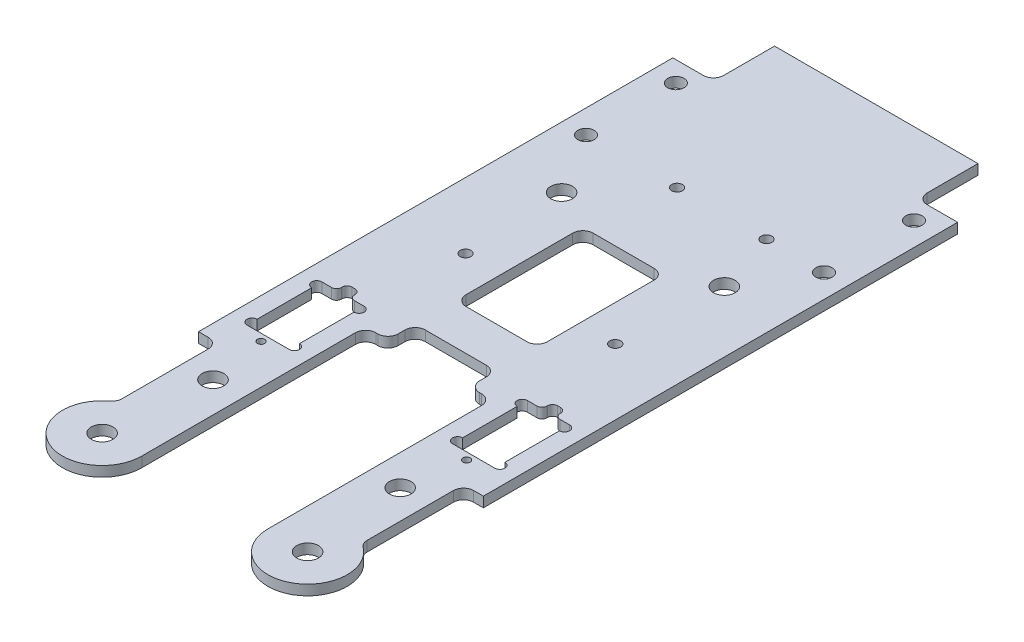
from build123d import *

# Parameters (mm, degrees)
SKETCH1_W           = 88.9
SKETCH1_H           = 228.6
BOSS_EXTRUDE1_DEPTH = 3.175
SKETCH12_R          = 3.3782
SKETCH12_W          = 39.37
SKETCH12_H          = 63.5
CUT_EXTRUDE13_DEPTH = 4.175
SKETCH14_R          = 2.5527
CUT_EXTRUDE15_DEPTH = 4.175
SKETCH15_W          = 88.9
SKETCH15_H          = 57.15
CUT_EXTRUDE16_DEPTH = 4.175
FILLET1_R           = 3.175
SKETCH18_R          = 1.6891
CUT_EXTRUDE18_DEPTH = 4.175
SKETCH16_R          = 3.3782
BOSS_EXTRUDE2_DEPTH = 3.175
SKETCH19_R          = 3.3782
CUT_EXTRUDE19_DEPTH = 4.175
SKETCH20_R          = 1.143
CUT_EXTRUDE20_DEPTH = 4.175
SKETCH21_W          = 88.9
SKETCH21_H          = 3.175
BOSS_EXTRUDE3_DEPTH = 19.05
CUT_EXTRUDE21_DEPTH = 4.175
CUT_EXTRUDE22_DEPTH = 4.175


with BuildPart() as part:
    # Sketch1 → Boss-Extrude1 (new body)
    with BuildSketch(Plane(origin=(0, 0, 0), x_dir=(1, 0, 0), z_dir=(0, 1, 0))):
        Rectangle(SKETCH1_W, SKETCH1_H)
    extrude(amount=BOSS_EXTRUDE1_DEPTH)

    # Sketch12 → Cut-Extrude13 (cut, through all)
    with BuildSketch(Plane(origin=(0, 3.175, 0), x_dir=(1, 0, 0), z_dir=(0, 1, 0))):
        with Locations((29.21, -44.45)):
            Circle(SKETCH12_R)
        with Locations((-29.21, -44.45)):
            Circle(SKETCH12_R)
        with Locations((0, -38.1)):
            Rectangle(SKETCH12_W, SKETCH12_H)
    extrude(amount=-CUT_EXTRUDE13_DEPTH, mode=Mode.SUBTRACT)

    # Sketch14 → Cut-Extrude15 (cut, through all)
    with BuildSketch(Plane(origin=(0, 0, 0), x_dir=(-1, 0, 0), z_dir=(0, -1, 0))):
        with Locations((-37.1475, 107.95)):
            Circle(SKETCH14_R)
        with Locations((-37.1475, 79.883)):
            Circle(SKETCH14_R)
        with Locations((37.1475, 107.95)):
            Circle(SKETCH14_R)
        with Locations((37.1475, 79.883)):
            Circle(SKETCH14_R)
    extrude(amount=-CUT_EXTRUDE15_DEPTH, mode=Mode.SUBTRACT)

    # Sketch15 → Cut-Extrude16 (cut, through all)
    with BuildSketch(Plane.XZ):
        with Locations((0, 85.725)):
            Rectangle(SKETCH15_W, SKETCH15_H)
        with BuildLine():
            Line((12.7, -51.308), (12.7, -17.991666667))
            ThreePointArc((12.7, -17.991666667), (11.77006403, -15.746602636), (9.525, -14.816666667))
            Line((9.525, -14.816666667), (-9.525, -14.816666667))
            ThreePointArc((-9.525, -14.816666667), (-11.77006403, -15.746602636), (-12.7, -17.991666667))
            Line((-12.7, -17.991666667), (-12.7, -51.308))
            ThreePointArc((-12.7, -51.308), (-11.77006403, -53.55306403), (-9.525, -54.483))
            Line((-9.525, -54.483), (9.525, -54.483))
            ThreePointArc((9.525, -54.483), (11.77006403, -53.55306403), (12.7, -51.308))
        make_face()
        with BuildLine():
            Line((12.7, 6.35), (-12.7, 6.35))
            Line((-12.7, 6.35), (-12.7, 1.058333333))
            ThreePointArc((-12.7, 1.058333333), (-11.77006403, -1.186730697), (-9.525, -2.116666667))
            Line((-9.525, -2.116666667), (9.525, -2.116666667))
            ThreePointArc((9.525, -2.116666667), (11.77006403, -1.186730697), (12.7, 1.058333333))
            Line((12.7, 1.058333333), (12.7, 6.35))
        make_face()
    extrude(amount=-CUT_EXTRUDE16_DEPTH, mode=Mode.SUBTRACT)

    # Fillet1
    fillet1_edges = [part.edges().sort_by_distance(p)[0] for p in [
        (19.685, 1.5875, 6.35),
        (-19.685, 1.5875, 6.35),
        (-12.7, 1.5875, 6.35),
        (12.7, 1.5875, 6.35),
    ]]
    fillet(fillet1_edges, radius=FILLET1_R)

    # Sketch18 → Cut-Extrude18 (cut, through all)
    with BuildSketch(Plane(origin=(0, 3.175, 0), x_dir=(1, 0, 0), z_dir=(0, 1, 0))):
        with Locations((-23.9014, 29.083)):
            Circle(SKETCH18_R)
        with Locations((23.9014, 27.98318)):
            Circle(SKETCH18_R)
        with Locations((-8.70204, 79.883)):
            Circle(SKETCH18_R)
        with Locations((19.19986, 79.883)):
            Circle(SKETCH18_R)
    extrude(amount=-CUT_EXTRUDE18_DEPTH, mode=Mode.SUBTRACT)

    # Sketch16 → Boss-Extrude2 (add)
    with BuildSketch(Plane(origin=(0, 3.175, 0), x_dir=(1, 0, 0), z_dir=(0, 1, 0))):
        with BuildLine():
            Line((-44.45, -57.15), (-44.45, -76.2))
            ThreePointArc((-44.45, -76.2), (-32.0675, -88.5825), (-19.685, -76.2))
            Line((-19.685, -76.2), (-19.685, -57.15))
            Line((-19.685, -57.15), (-44.45, -57.15))
        make_face()
        with Locations((-32.0675, -76.2)):
            Circle(SKETCH16_R, mode=Mode.SUBTRACT)
        with BuildLine():
            ThreePointArc((44.45, -76.2), (32.0675, -88.5825), (19.685, -76.2))
            Line((19.685, -76.2), (19.685, -57.15))
            Line((19.685, -57.15), (44.45, -57.15))
            Line((44.45, -57.15), (44.45, -76.2))
        make_face()
        with Locations((32.0675, -76.2)):
            Circle(SKETCH16_R, mode=Mode.SUBTRACT)
    extrude(amount=-BOSS_EXTRUDE2_DEPTH)

    # Sketch19 → Cut-Extrude19 (cut, through all)
    with BuildSketch(Plane(origin=(0, 3.175, 0), x_dir=(1, 0, 0), z_dir=(0, 1, 0))):
        with Locations((-25.4, 60.536666667)):
            Circle(SKETCH19_R)
        with Locations((25.4, 60.536666667)):
            Circle(SKETCH19_R)
    extrude(amount=-CUT_EXTRUDE19_DEPTH, mode=Mode.SUBTRACT)

    # Sketch20 → Cut-Extrude20 (cut, through all)
    with BuildSketch(Plane(origin=(0, 3.175, 0), x_dir=(1, 0, 0), z_dir=(0, 1, 0))):
        with Locations((-32.0675, -26.58657951)):
            Circle(SKETCH20_R)
        with Locations((32.0675, -26.58657951)):
            Circle(SKETCH20_R)
        with BuildLine():
            Line((-25.4635, -24.384), (-38.6715, -24.384))
            ThreePointArc((-38.6715, -24.384), (-40.259, -22.7965), (-38.6715, -21.209))
            Line((-38.6715, -21.209), (-38.6715, -4.191))
            ThreePointArc((-38.6715, -4.191), (-40.259, -2.6035), (-38.6715, -1.016))
            Line((-38.6715, -1.016), (-35.687, -1.016))
            ThreePointArc((-35.687, -1.016), (-34.564467985, -0.551032015), (-34.0995, 0.5715))
            Line((-34.0995, 0.5715), (-34.0995, 0.6985))
            ThreePointArc((-34.0995, 0.6985), (-33.634532015, 1.821032015), (-32.512, 2.286))
            Line((-32.512, 2.286), (-31.623, 2.286))
            ThreePointArc((-31.623, 2.286), (-30.500467985, 1.821032015), (-30.0355, 0.6985))
            Line((-30.0355, 0.6985), (-30.0355, 0.5715))
            ThreePointArc((-30.0355, 0.5715), (-29.570532015, -0.551032015), (-28.448, -1.016))
            Line((-28.448, -1.016), (-25.4635, -1.016))
            ThreePointArc((-25.4635, -1.016), (-23.876, -2.6035), (-25.4635, -4.191))
            Line((-25.4635, -4.191), (-25.4635, -21.209))
            ThreePointArc((-25.4635, -21.209), (-23.876, -22.7965), (-25.4635, -24.384))
        make_face()
        with BuildLine():
            Line((25.4635, -24.384), (38.6715, -24.384))
            ThreePointArc((38.6715, -24.384), (40.259, -22.7965), (38.6715, -21.209))
            Line((38.6715, -21.209), (38.6715, -4.191))
            ThreePointArc((38.6715, -4.191), (40.259, -2.6035), (38.6715, -1.016))
            Line((38.6715, -1.016), (35.687, -1.016))
            ThreePointArc((35.687, -1.016), (34.564467985, -0.551032015), (34.0995, 0.5715))
            Line((34.0995, 0.5715), (34.0995, 0.6985))
            ThreePointArc((34.0995, 0.6985), (33.634532015, 1.821032015), (32.512, 2.286))
            Line((32.512, 2.286), (31.623, 2.286))
            ThreePointArc((31.623, 2.286), (30.500467985, 1.821032015), (30.0355, 0.6985))
            Line((30.0355, 0.6985), (30.0355, 0.5715))
            ThreePointArc((30.0355, 0.5715), (29.570532015, -0.551032015), (28.448, -1.016))
            Line((28.448, -1.016), (25.4635, -1.016))
            ThreePointArc((25.4635, -1.016), (23.876, -2.6035), (25.4635, -4.191))
            Line((25.4635, -4.191), (25.4635, -21.209))
            ThreePointArc((25.4635, -21.209), (23.876, -22.7965), (25.4635, -24.384))
        make_face()
    extrude(amount=-CUT_EXTRUDE20_DEPTH, mode=Mode.SUBTRACT)

    # Sketch21 → Boss-Extrude3 (add)
    with BuildSketch(Plane(origin=(0, 0, -114.3), x_dir=(-1, 0, 0), z_dir=(0, 0, -1))):
        with Locations((0, 1.5875)):
            Rectangle(SKETCH21_W, SKETCH21_H)
    extrude(amount=BOSS_EXTRUDE3_DEPTH)

    # Sketch22 → Cut-Extrude21 (cut, through all)
    with BuildSketch(Plane(origin=(0, 3.175, 0), x_dir=(1, 0, 0), z_dir=(0, 1, 0))):
        with BuildLine():
            Line((-44.45, 133.35), (-31.75, 133.35))
            Line((-31.75, 133.35), (-31.75, 117.475))
            ThreePointArc((-31.75, 117.475), (-32.67993597, 115.22993597), (-34.925, 114.3))
            Line((-34.925, 114.3), (-44.45, 114.3))
            Line((-44.45, 114.3), (-44.45, 133.35))
        make_face()
        with BuildLine():
            Line((44.45, 114.3), (34.925, 114.3))
            ThreePointArc((34.925, 114.3), (32.67993597, 115.22993597), (31.75, 117.475))
            Line((31.75, 117.475), (31.75, 133.35))
            Line((31.75, 133.35), (44.45, 133.35))
            Line((44.45, 133.35), (44.45, 114.3))
        make_face()
    extrude(amount=-CUT_EXTRUDE21_DEPTH, mode=Mode.SUBTRACT)

    # Sketch23 → Cut-Extrude22 (cut, through all)
    with BuildSketch(Plane(origin=(0, 3.175, 0), x_dir=(1, 0, 0), z_dir=(0, 1, 0))):
        with BuildLine():
            Line((-38.25875, -63.777875899), (-38.25875, -36.901440438))
            ThreePointArc((-38.25875, -36.901440438), (-39.18868597, -34.656376407), (-41.43375, -33.726440438))
            Line((-41.43375, -33.726440438), (-44.45, -33.726440438))
            Line((-44.45, -33.726440438), (-44.45, -76.2))
            ThreePointArc((-44.45, -76.2), (-43.149805735, -70.676522306), (-39.522270408, -66.313003266))
            ThreePointArc((-39.522270408, -66.313003266), (-38.592133145, -65.194152231), (-38.25875, -63.777875899))
        make_face()
        with BuildLine():
            Line((41.43375, -33.726440438), (44.45, -33.726440438))
            Line((44.45, -33.726440438), (44.45, -76.2))
            ThreePointArc((44.45, -76.2), (43.149805735, -70.676522306), (39.522270408, -66.313003266))
            ThreePointArc((39.522270408, -66.313003266), (38.592133145, -65.194152231), (38.25875, -63.777875899))
            Line((38.25875, -63.777875899), (38.25875, -36.901440438))
            ThreePointArc((38.25875, -36.901440438), (39.18868597, -34.656376407), (41.43375, -33.726440438))
        make_face()
    extrude(amount=-CUT_EXTRUDE22_DEPTH, mode=Mode.SUBTRACT)


solid = part.part
